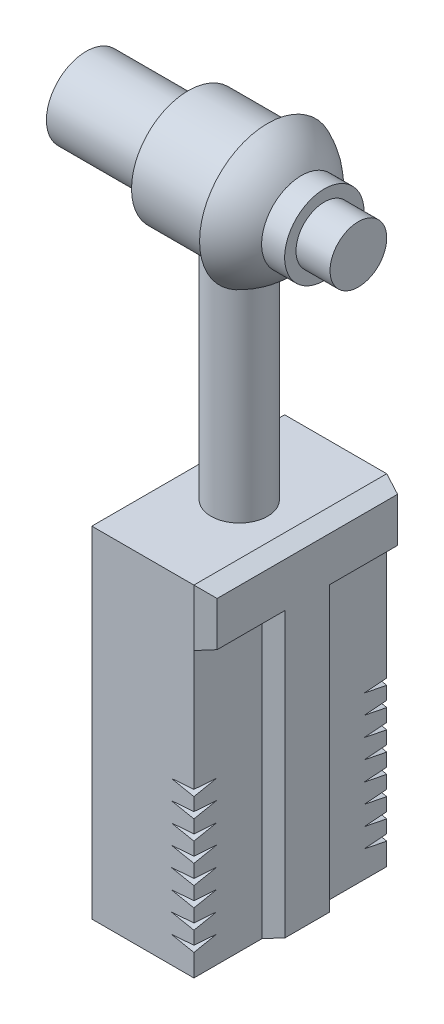
from build123d import *

# Parameters (mm, degrees)
SKETCH2_W                = 17
SKETCH2_H                = 30
BOSS_EXTRUDE1_DEPTH      = 4.5
SHELL1_T                 = -0.75
LPATTERN1_COUNT          = 8
LPATTERN1_PITCH          = 1.7
SKETCH7_R                = 5
BOSS_EXTRUDE3_DEPTH      = 7
BOSS_EXTRUDE2_REACH      = 33.851
BOSS_EXTRUDE2_END_RADIUS = 5
SKETCH3_R                = 2.5
SKETCH8_R                = 3.5
BOSS_EXTRUDE4_DEPTH      = 9
SKETCH9_R                = 3.5
BOSS_EXTRUDE5_DEPTH      = 5
SKETCH11_R               = 2.5
BOSS_EXTRUDE6_DEPTH      = 3
BOSS_EXTRUDE7_DEPTH      = 1.5
BOSS_EXTRUDE7_TAPER      = 20


with BuildPart() as part:
    # Sketch2 → Boss-Extrude1 (new, symmetric)
    with BuildSketch(Plane(origin=(0, 0, 0), x_dir=(0, 0, -1), z_dir=(1, 0, 0))):
        Rectangle(SKETCH2_W, SKETCH2_H)
    extrude(amount=BOSS_EXTRUDE1_DEPTH, both=True)

    # Shell1
    shell1_openings = [part.faces().sort_by_distance(p)[0] for p in [
        (0, -15, 0),
    ]]
    offset(amount=SHELL1_T, openings=shell1_openings, kind=Kind.INTERSECTION)

    # Sketch12 → Cut-Revolve1 (revolve, cut)
    with BuildSketch(Plane.XY.offset(8.5)):
        Polygon((4.5, -12.5), (2.5, -12.65), (4.5, -13.05), align=None)
    cut_revolve1 = revolve(axis=Axis((4.5, -15, 8.5), (0, 1, 0)), mode=Mode.SUBTRACT)

    # LPattern1: Cut-Revolve1 ×8
    with Locations(*[(0, i * LPATTERN1_PITCH, 0) for i in range(1, LPATTERN1_COUNT)]):
        add(cut_revolve1, mode=Mode.SUBTRACT)

    # Boss-Extrude2: up to this cylinder (the profile starts outside it)
    boss_extrude2_end = Plane(origin=(0, 39, 0), z_dir=(1, 0, 0)) * Cylinder(BOSS_EXTRUDE2_END_RADIUS, 78.702, mode=Mode.PRIVATE)
    # Sketch3 → Boss-Extrude2 (add, up to the surface)
    with BuildSketch(Plane(origin=(0, 15, 0), x_dir=(1, 0, 0), z_dir=(0, 1, 0)), mode=Mode.PRIVATE) as boss_extrude2_sk1:
        with Locations(Location((0, 0, 0), (0, 0, 90))):
            Circle(SKETCH3_R)
    boss_extrude2_tool1 = extrude(boss_extrude2_sk1.sketch, amount=BOSS_EXTRUDE2_REACH, mode=Mode.PRIVATE) - boss_extrude2_end
    add(boss_extrude2_tool1.solids().sort_by_distance((0, 15, 0))[0])

    # Sketch13 → Boss-Extrude7 (add)
    with BuildSketch(Plane(origin=(4.5, 0, 0), x_dir=(0, 0, -1), z_dir=(1, 0, 0))):
        Polygon((-8.5, 15), (-8.5, 10), (-2.5, 10), (-2.5, -15), (2.5, -15), (2.5, 10), (8.5, 10), (8.5, 15), align=None)
    extrude(amount=BOSS_EXTRUDE7_DEPTH, taper=BOSS_EXTRUDE7_TAPER)

    # Mirror1: Cut-Revolve1 across plane
    add(cut_revolve1.mirror(Plane.XY), mode=Mode.SUBTRACT)

    # Mirror1 copy 1 sketch → Mirror1 copy 1 (revolve, cut)
    with BuildSketch(Plane(origin=(0, 1.7, -8.5), x_dir=(1, 0, 0), z_dir=(0, 0, -1))):
        Polygon((4.5, 12.5), (2.5, 12.65), (4.5, 13.05), align=None)
    revolve(axis=Axis((4.5, -13.3, -8.5), (0, -1, 0)), mode=Mode.SUBTRACT)

    # Mirror1 copy 2 sketch → Mirror1 copy 2 (revolve, cut)
    with BuildSketch(Plane(origin=(0, 3.4, -8.5), x_dir=(1, 0, 0), z_dir=(0, 0, -1))):
        Polygon((4.5, 12.5), (2.5, 12.65), (4.5, 13.05), align=None)
    revolve(axis=Axis((4.5, -11.6, -8.5), (0, -1, 0)), mode=Mode.SUBTRACT)

    # Mirror1 copy 3 sketch → Mirror1 copy 3 (revolve, cut)
    with BuildSketch(Plane(origin=(0, 5.1, -8.5), x_dir=(1, 0, 0), z_dir=(0, 0, -1))):
        Polygon((4.5, 12.5), (2.5, 12.65), (4.5, 13.05), align=None)
    revolve(axis=Axis((4.5, -9.9, -8.5), (0, -1, 0)), mode=Mode.SUBTRACT)

    # Mirror1 copy 4 sketch → Mirror1 copy 4 (revolve, cut)
    with BuildSketch(Plane(origin=(0, 6.8, -8.5), x_dir=(1, 0, 0), z_dir=(0, 0, -1))):
        Polygon((4.5, 12.5), (2.5, 12.65), (4.5, 13.05), align=None)
    revolve(axis=Axis((4.5, -8.2, -8.5), (0, -1, 0)), mode=Mode.SUBTRACT)

    # Mirror1 copy 5 sketch → Mirror1 copy 5 (revolve, cut)
    with BuildSketch(Plane(origin=(0, 8.5, -8.5), x_dir=(1, 0, 0), z_dir=(0, 0, -1))):
        Polygon((4.5, 12.5), (2.5, 12.65), (4.5, 13.05), align=None)
    revolve(axis=Axis((4.5, -6.5, -8.5), (0, -1, 0)), mode=Mode.SUBTRACT)

    # Mirror1 copy 6 sketch → Mirror1 copy 6 (revolve, cut)
    with BuildSketch(Plane(origin=(0, 10.2, -8.5), x_dir=(1, 0, 0), z_dir=(0, 0, -1))):
        Polygon((4.5, 12.5), (2.5, 12.65), (4.5, 13.05), align=None)
    revolve(axis=Axis((4.5, -4.8, -8.5), (0, -1, 0)), mode=Mode.SUBTRACT)

    # Mirror1 copy 7 sketch → Mirror1 copy 7 (revolve, cut)
    with BuildSketch(Plane(origin=(0, 11.9, -8.5), x_dir=(1, 0, 0), z_dir=(0, 0, -1))):
        Polygon((4.5, 12.5), (2.5, 12.65), (4.5, 13.05), align=None)
    revolve(axis=Axis((4.5, -3.1, -8.5), (0, -1, 0)), mode=Mode.SUBTRACT)


with BuildPart() as body_2:
    # Sketch5 → Revolve1 (revolve)
    with BuildSketch(Plane(origin=(0, 39, 0), x_dir=(1, 0, 0), z_dir=(0, 1, 0)), mode=Mode.PRIVATE) as revolve1_sk:
        with BuildLine():
            Line((2.5, 0), (2.5, 6))
            ThreePointArc((2.5, 6), (5.408326913, 3.605551275), (6.5, 0))
            Line((6.5, 0), (2.5, 0))
        make_face()
    revolve(revolve1_sk.sketch.rotate(Axis((16.74985483, 39, 0), (-1, 0, 0)), 180), axis=Axis((16.74985483, 39, 0), (-1, 0, 0)))

    # Sketch7 → Boss-Extrude3 (add)
    with BuildSketch(Plane.ZY.offset(-2.5)):
        with Locations((0, 39)):
            Circle(SKETCH7_R)
    extrude(amount=BOSS_EXTRUDE3_DEPTH)

    # Sketch8 → Boss-Extrude4 (add)
    with BuildSketch(Plane.ZY.offset(4.5)):
        with Locations((0, 39)):
            Circle(SKETCH8_R)
    extrude(amount=BOSS_EXTRUDE4_DEPTH)


with BuildPart() as body_3:
    # Sketch9 → Boss-Extrude5 (new body)
    with BuildSketch(Plane(origin=(2.5, 0, 0), x_dir=(0, 0, -1), z_dir=(1, 0, 0))):
        with Locations((0, 39)):
            Circle(SKETCH9_R)
    extrude(amount=BOSS_EXTRUDE5_DEPTH)


with BuildPart() as body_4:
    # Sketch11 → Boss-Extrude6 (new body)
    with BuildSketch(Plane(origin=(7.5, 0, 0), x_dir=(0, 0, -1), z_dir=(1, 0, 0))):
        with Locations((0, 39)):
            Circle(SKETCH11_R)
    extrude(amount=BOSS_EXTRUDE6_DEPTH)


solid = Compound([part.part, body_2.part, body_3.part, body_4.part])
